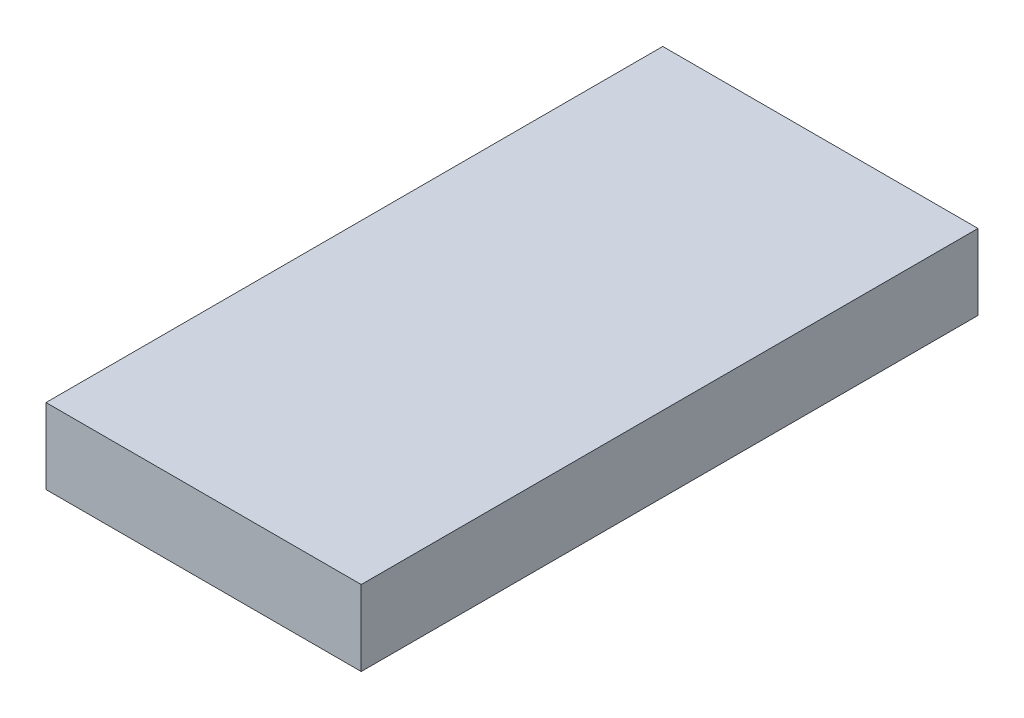
from build123d import *

# Parameters (mm, degrees)
SKETCH1_W           = 460
SKETCH1_H           = 900
BOSS_EXTRUDE1_DEPTH = 110


with BuildPart() as part:
    # Sketch1 → Boss-Extrude1 (new body)
    with BuildSketch(Plane(origin=(0, 0, 0), x_dir=(1, 0, 0), z_dir=(0, 1, 0))):
        Rectangle(SKETCH1_W, SKETCH1_H)
    extrude(amount=BOSS_EXTRUDE1_DEPTH)


solid = part.part
